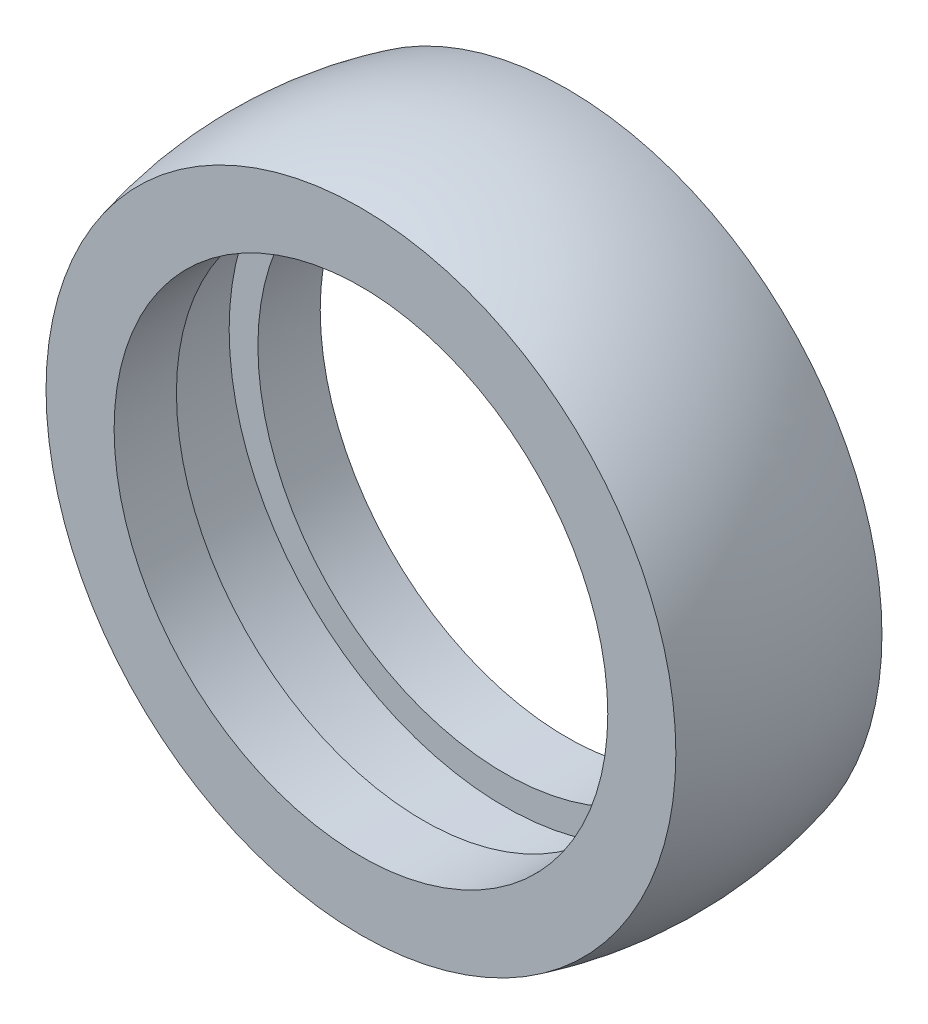
from build123d import *


with BuildPart() as part:
    # Sketch1 → Revolve1 (revolve)
    with BuildSketch(Plane(origin=(0, 0, 0), x_dir=(0, 0, -1), z_dir=(1, 0, 0))):
        with BuildLine():
            Line((-10.75, 25.75), (-4.25, 25.75))
            Line((-4.25, 25.75), (-4.25, 28.75))
            Line((-4.25, 28.75), (4.25, 28.75))
            Line((4.25, 28.75), (4.25, 25.75))
            Line((4.25, 25.75), (10.75, 25.75))
            Line((10.75, 25.75), (10.75, 32.850954422))
            ThreePointArc((10.75, 32.850954422), (0, 34.25), (-10.75, 32.850954422))
            Line((-10.75, 32.850954422), (-10.75, 25.75))
        make_face()
    revolve(axis=Axis((0, 0, 733.316005498), (0, 0, -1)))


solid = part.part
